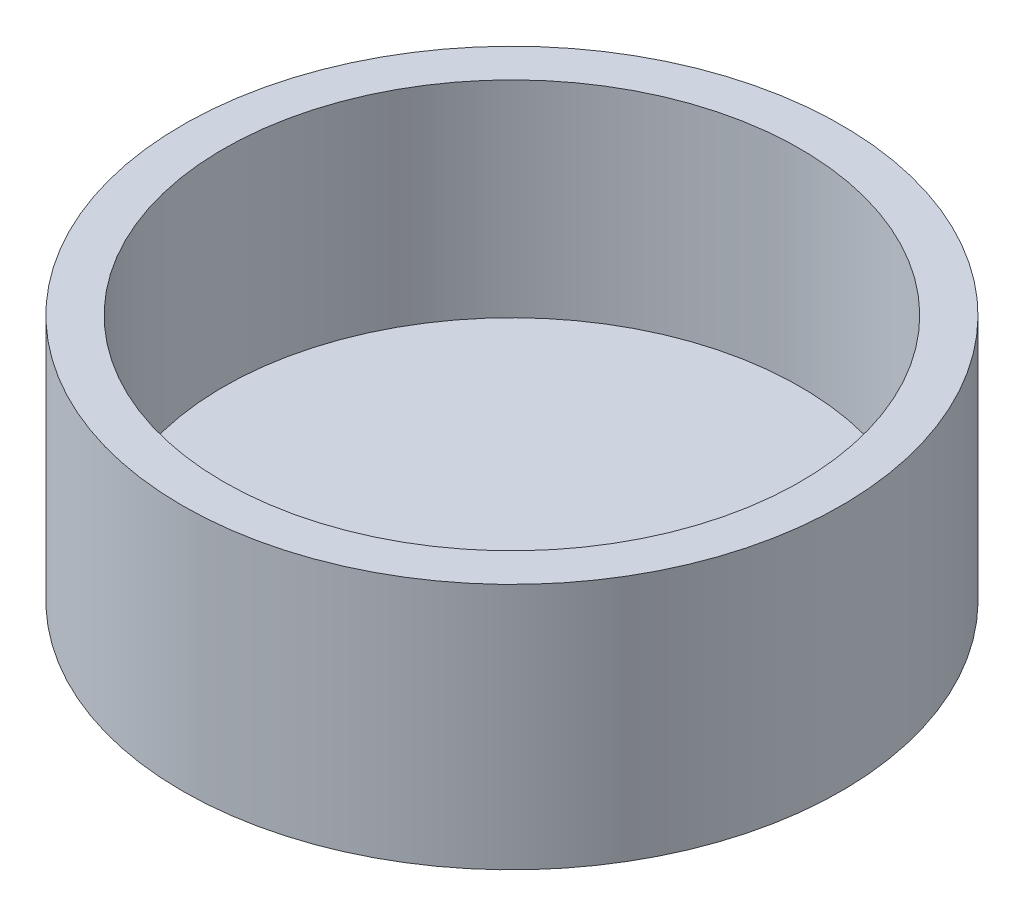
from build123d import *

# Parameters (mm, degrees)
SKETCH1_R           = 101.6
BOSS_EXTRUDE1_DEPTH = 76.2
SKETCH2_R           = 88.9
CUT_EXTRUDE1_DEPTH  = 63.5
SKETCH3_R           = 12.7
SKETCH3_R_2         = 9.525
BOSS_EXTRUDE2_DEPTH = 25.4


with BuildPart() as part:
    # Sketch1 → Boss-Extrude1 (new body)
    with BuildSketch(Plane(origin=(0, 0, 0), x_dir=(1, 0, 0), z_dir=(0, 1, 0))):
        Circle(SKETCH1_R)
    extrude(amount=BOSS_EXTRUDE1_DEPTH)

    # Sketch2 → Cut-Extrude1 (cut)
    with BuildSketch(Plane(origin=(0, 76.2, 0), x_dir=(1, 0, 0), z_dir=(0, 1, 0))):
        Circle(SKETCH2_R)
    extrude(amount=-CUT_EXTRUDE1_DEPTH, mode=Mode.SUBTRACT)

    # Sketch3 → Boss-Extrude2 (add)
    with BuildSketch(Plane.XZ):
        Circle(SKETCH3_R)
        Circle(SKETCH3_R_2, mode=Mode.SUBTRACT)
    extrude(amount=BOSS_EXTRUDE2_DEPTH)


solid = part.part
